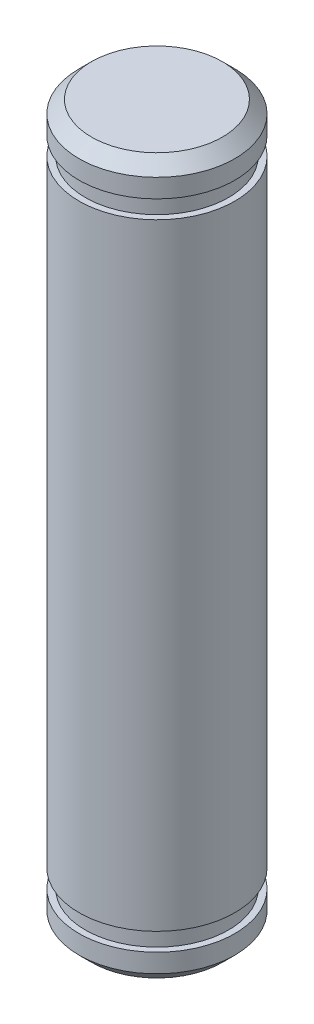
from build123d import *

# Parameters (mm, degrees)
CHAMFER1_SIZE = 0.508


with BuildPart() as part:
    # Sketch1 → Revolve1 (revolve)
    with BuildSketch(Plane.XY):
        Polygon((-3.175, 12.5603), (-3.175, -12.5603), (-2.921, -12.5603), (-2.921, -13.2969), (-3.175, -13.2969), (-3.175, -14.5669), (0, -14.5669), (0, 14.5669), (-3.175, 14.5669), (-3.175, 13.2969), (-2.921, 13.2969), (-2.921, 12.5603), align=None)
    revolve(axis=Axis((0, 14.5669, 0), (0, -1, 0)))

    # Chamfer1
    chamfer1_edges = [part.edges().sort_by_distance(p)[0] for p in [
        (3.175, -14.5669, 0),
        (3.175, 14.5669, 0),
    ]]
    chamfer(chamfer1_edges, length=CHAMFER1_SIZE)


solid = part.part
